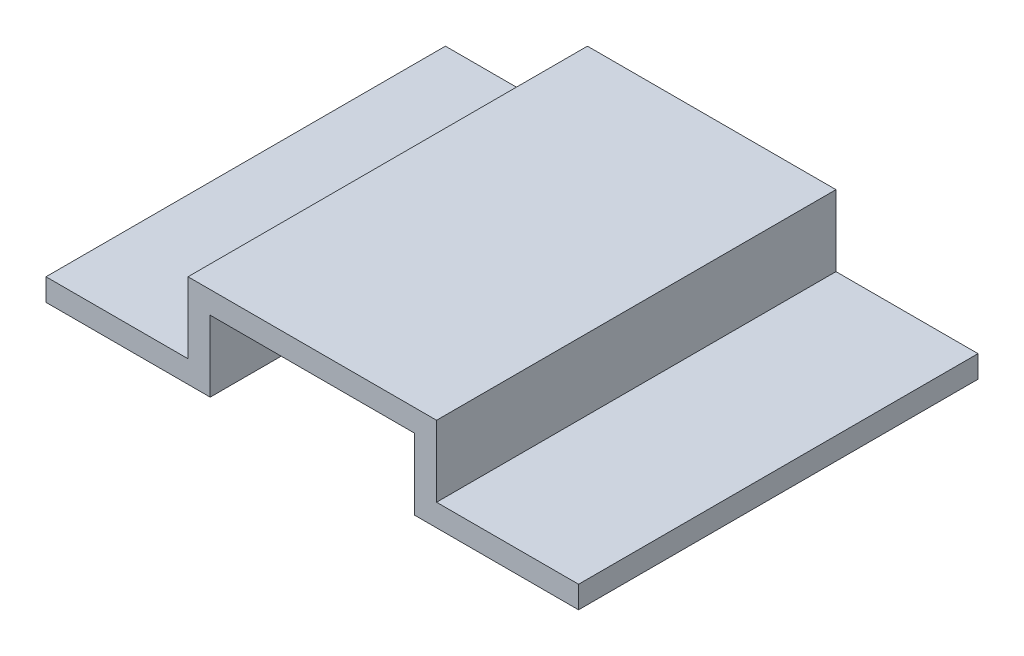
from build123d import *

# Parameters (mm, degrees)
BOSS_EXTRUDE1_DEPTH = 450


with BuildPart() as part:
    # Sketch1 → Boss-Extrude1 (new body)
    with BuildSketch(Plane.XY):
        Polygon((50, 0), (235, 0), (235, 80), (465, 80), (465, 0), (650, 0), (650, 25), (490, 25), (490, 105), (210, 105), (210, 25), (50, 25), align=None)
    extrude(amount=BOSS_EXTRUDE1_DEPTH)


solid = part.part
